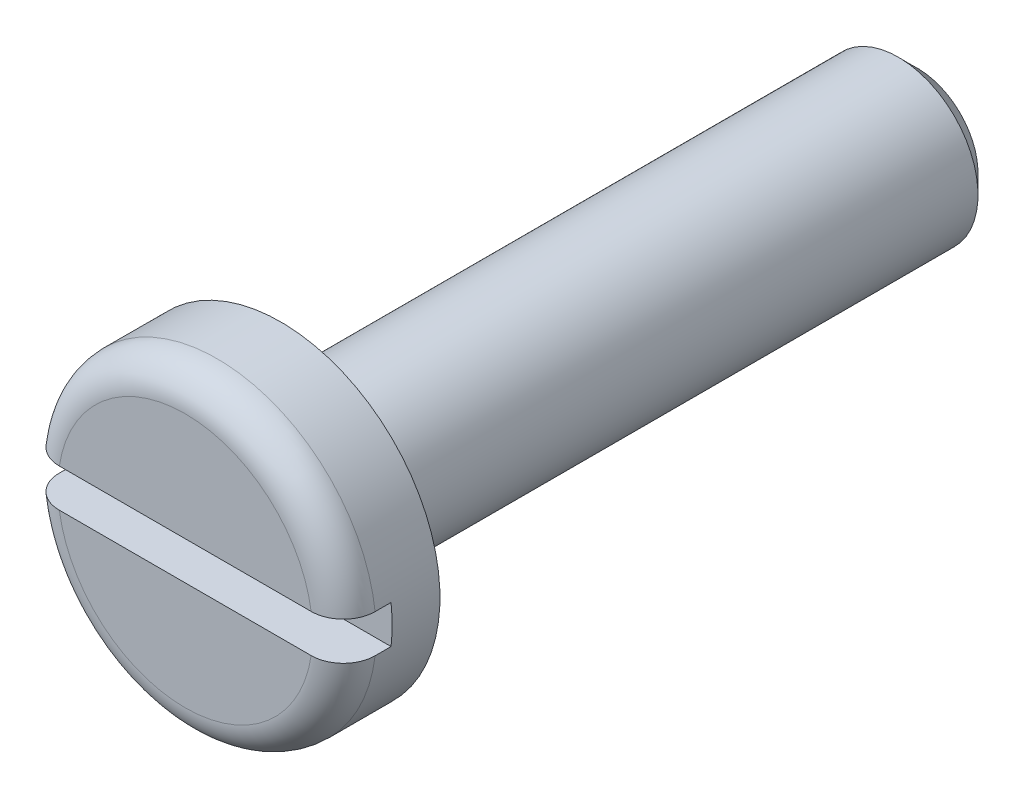
from build123d import *

# Parameters (mm, degrees)
SKETCH_2_W               = 1.5
SKETCH_2_H               = 1.2
CUT_EXTRUDE_1_DEPTH      = 6
CUT_EXTRUDE_1_DEPTH_BACK = 6
CHAMFER_1_SIZE           = 0.6
FILLET_1_R               = 1
FILLET_2_R               = 0.4


with BuildPart() as part:
    # Эскиз1 → Повернуть1 (revolve)
    with BuildSketch(Plane(origin=(0, 0, 0), x_dir=(1, 0, 0), z_dir=(0, 1, 0))):
        Polygon((0, 0), (-5, 0), (-5, 3), (-2.5, 3), (-2.5, 23), (0, 23), align=None)
    revolve(axis=Axis((0, 0, -23), (0, 0, 1)))

    # Эскиз2 → Вырез-Вытянуть1 (cut, two sides)
    with BuildSketch(Plane(origin=(0, 0, 0), x_dir=(0, 0, -1), z_dir=(1, 0, 0))) as cut_extrude_1_sk:
        with Locations((0.75, 0)):
            Rectangle(SKETCH_2_W, SKETCH_2_H)
    extrude(amount=CUT_EXTRUDE_1_DEPTH, mode=Mode.SUBTRACT)
    extrude(cut_extrude_1_sk.sketch, amount=-CUT_EXTRUDE_1_DEPTH_BACK, mode=Mode.SUBTRACT)

    # Фаска1
    chamfer_1_edges = [part.edges().sort_by_distance(p)[0] for p in [
        (2.5, 0, -23),
    ]]
    chamfer(chamfer_1_edges, length=CHAMFER_1_SIZE)

    # Скругление1
    fillet_1_edges = [part.edges().sort_by_distance(p)[0] for p in [
        (0, 5, 0),
        (0, -5, 0),
    ]]
    fillet(fillet_1_edges, radius=FILLET_1_R)

    # Скругление2
    fillet_2_edges = [part.edges().sort_by_distance(p)[0] for p in [
        (2.5, 0, -3),
    ]]
    fillet(fillet_2_edges, radius=FILLET_2_R)


solid = part.part
